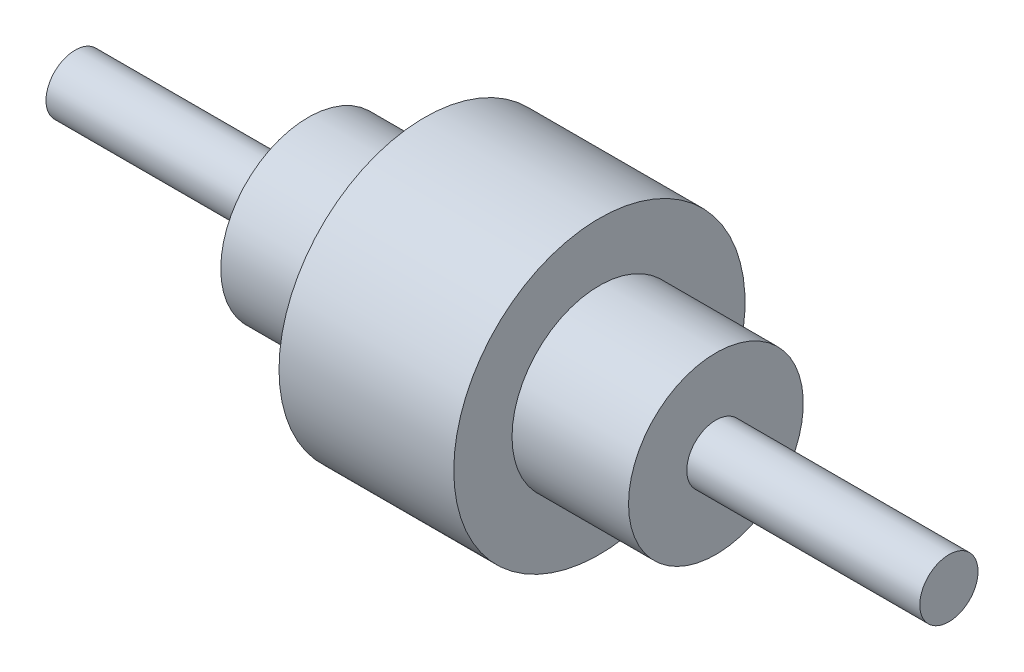
from build123d import *


with BuildPart() as part:
    # Sketch1 → Revolve1 (revolve)
    with BuildSketch(Plane(origin=(0, 0, 0), x_dir=(1, 0, 0), z_dir=(0, 1, 0)), mode=Mode.PRIVATE) as revolve1_sk:
        Polygon((0, 0), (0, 10), (80, 10), (80, 30), (120, 30), (120, 50), (180, 50), (180, 30), (220, 30), (220, 10), (300, 10), (300, 0), align=None)
    revolve(revolve1_sk.sketch.rotate(Axis((0, 0, 0), (1, 0, 0)), 180), axis=Axis((0, 0, 0), (1, 0, 0)))  # turned: the seam where the file's is


solid = part.part
